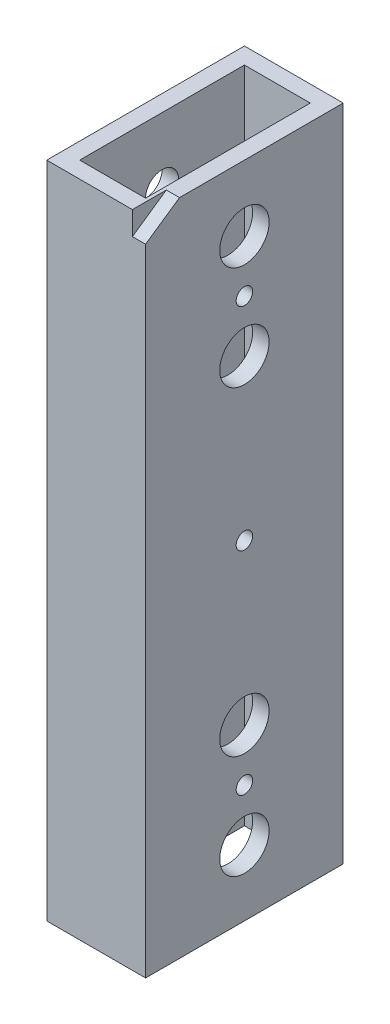
from build123d import *

# Parameters (mm, degrees)
SKETCH1_W           = 19.05
SKETCH1_H           = 38.1
SKETCH1_W_2         = 12.7
SKETCH1_H_2         = 31.75
BOSS_EXTRUDE1_DEPTH = 127
SKETCH2_R           = 3.175
CUT_EXTRUDE1_DEPTH  = 20.05
CUT_EXTRUDE2_REACH  = 21.05
SKETCH3_R           = 4.7625
SKETCH4_R           = 1.5875
UCHAN_MOUNT_DEPTH   = 20.05
CUT_EXTRUDE4_REACH  = 21.05
SKETCH5_R           = 4.7625
CUT_EXTRUDE5_DEPTH  = 2.54


with BuildPart() as part:
    # Sketch1 → Boss-Extrude1 (new body)
    with BuildSketch(Plane(origin=(0, 0, 0), x_dir=(1, 0, 0), z_dir=(0, 1, 0))):
        with Locations((9.525, 19.05)):
            Rectangle(SKETCH1_W, SKETCH1_H)
        with Locations((9.525, 19.05)):
            Rectangle(SKETCH1_W_2, SKETCH1_H_2, mode=Mode.SUBTRACT)
    extrude(amount=BOSS_EXTRUDE1_DEPTH)

    # Sketch2 → Cut-Extrude1 (cut, through all)
    with BuildSketch(Plane(origin=(19.05, 0, 0), x_dir=(0, 0, -1), z_dir=(1, 0, 0))):
        with Locations((19.05, 12.7)):
            Circle(SKETCH2_R)
        with Locations((19.05, 32.69996)):
            Circle(SKETCH2_R)
        with Locations((19.05, 94.30004)):
            Circle(SKETCH2_R)
        with Locations((19.05, 114.3)):
            Circle(SKETCH2_R)
    extrude(amount=-CUT_EXTRUDE1_DEPTH, mode=Mode.SUBTRACT)

    # Sketch3 → Cut-Extrude2 (cut, up to next)
    with BuildSketch(Plane(origin=(19.05, 0, 0), x_dir=(0, 0, -1), z_dir=(1, 0, 0)), mode=Mode.PRIVATE) as cut_extrude2_sk1:
        with Locations((19.05, 114.3)):
            Circle(SKETCH3_R)
    cut_extrude2_tool1 = extrude(cut_extrude2_sk1.sketch, amount=-CUT_EXTRUDE2_REACH, mode=Mode.PRIVATE) & part.part
    add(cut_extrude2_tool1.solids().sort_by_distance((19.05, 114.3, -19.05))[0], mode=Mode.SUBTRACT)
    # Sketch3 → Cut-Extrude2 (cut, up to next)
    with BuildSketch(Plane(origin=(19.05, 0, 0), x_dir=(0, 0, -1), z_dir=(1, 0, 0)), mode=Mode.PRIVATE) as cut_extrude2_sk2:
        with Locations((19.05, 94.30004)):
            Circle(SKETCH3_R)
    cut_extrude2_tool2 = extrude(cut_extrude2_sk2.sketch, amount=-CUT_EXTRUDE2_REACH, mode=Mode.PRIVATE) & part.part
    add(cut_extrude2_tool2.solids().sort_by_distance((19.05, 94.30004, -19.05))[0], mode=Mode.SUBTRACT)
    # Sketch3 → Cut-Extrude2 (cut, up to next)
    with BuildSketch(Plane(origin=(19.05, 0, 0), x_dir=(0, 0, -1), z_dir=(1, 0, 0)), mode=Mode.PRIVATE) as cut_extrude2_sk3:
        with Locations((19.05, 32.69996)):
            Circle(SKETCH3_R)
    cut_extrude2_tool3 = extrude(cut_extrude2_sk3.sketch, amount=-CUT_EXTRUDE2_REACH, mode=Mode.PRIVATE) & part.part
    add(cut_extrude2_tool3.solids().sort_by_distance((19.05, 32.69996, -19.05))[0], mode=Mode.SUBTRACT)
    # Sketch3 → Cut-Extrude2 (cut, up to next)
    with BuildSketch(Plane(origin=(19.05, 0, 0), x_dir=(0, 0, -1), z_dir=(1, 0, 0)), mode=Mode.PRIVATE) as cut_extrude2_sk4:
        with Locations((19.05, 12.7)):
            Circle(SKETCH3_R)
    cut_extrude2_tool4 = extrude(cut_extrude2_sk4.sketch, amount=-CUT_EXTRUDE2_REACH, mode=Mode.PRIVATE) & part.part
    add(cut_extrude2_tool4.solids().sort_by_distance((19.05, 12.7, -19.05))[0], mode=Mode.SUBTRACT)

    # Sketch4 → UChan_Mount (cut, through all)
    with BuildSketch(Plane(origin=(19.05, 0, 0), x_dir=(0, 0, -1), z_dir=(1, 0, 0))):
        with Locations((19.05, 22.69998)):
            Circle(SKETCH4_R)
        with Locations((19.05, 63.5)):
            Circle(SKETCH4_R)
        with Locations((19.05, 104.30002)):
            Circle(SKETCH4_R)
    extrude(amount=-UCHAN_MOUNT_DEPTH, mode=Mode.SUBTRACT)

    # Sketch5 → Cut-Extrude4 (cut, up to next)
    with BuildSketch(Plane.ZY, mode=Mode.PRIVATE) as cut_extrude4_sk1:
        with Locations((-19.05, 104.30002)):
            Circle(SKETCH5_R)
    cut_extrude4_tool1 = extrude(cut_extrude4_sk1.sketch, amount=-CUT_EXTRUDE4_REACH, mode=Mode.PRIVATE) & part.part
    add(cut_extrude4_tool1.solids().sort_by_distance((0, 104.30002, -19.05))[0], mode=Mode.SUBTRACT)
    # Sketch5 → Cut-Extrude4 (cut, up to next)
    with BuildSketch(Plane.ZY, mode=Mode.PRIVATE) as cut_extrude4_sk2:
        with Locations((-19.05, 63.5)):
            Circle(SKETCH5_R)
    cut_extrude4_tool2 = extrude(cut_extrude4_sk2.sketch, amount=-CUT_EXTRUDE4_REACH, mode=Mode.PRIVATE) & part.part
    add(cut_extrude4_tool2.solids().sort_by_distance((0, 63.5, -19.05))[0], mode=Mode.SUBTRACT)
    # Sketch5 → Cut-Extrude4 (cut, up to next)
    with BuildSketch(Plane.ZY, mode=Mode.PRIVATE) as cut_extrude4_sk3:
        with Locations((-19.05, 22.69998)):
            Circle(SKETCH5_R)
    cut_extrude4_tool3 = extrude(cut_extrude4_sk3.sketch, amount=-CUT_EXTRUDE4_REACH, mode=Mode.PRIVATE) & part.part
    add(cut_extrude4_tool3.solids().sort_by_distance((0, 22.69998, -19.05))[0], mode=Mode.SUBTRACT)

    # Sketch6 → Cut-Extrude5 (cut)
    with BuildSketch(Plane(origin=(19.05, 0, 0), x_dir=(0, 0, -1), z_dir=(1, 0, 0))):
        Polygon((0, 127), (6.5373666, 127), (0, 122.48760451), align=None)
    extrude(amount=-CUT_EXTRUDE5_DEPTH, mode=Mode.SUBTRACT)


solid = part.part
